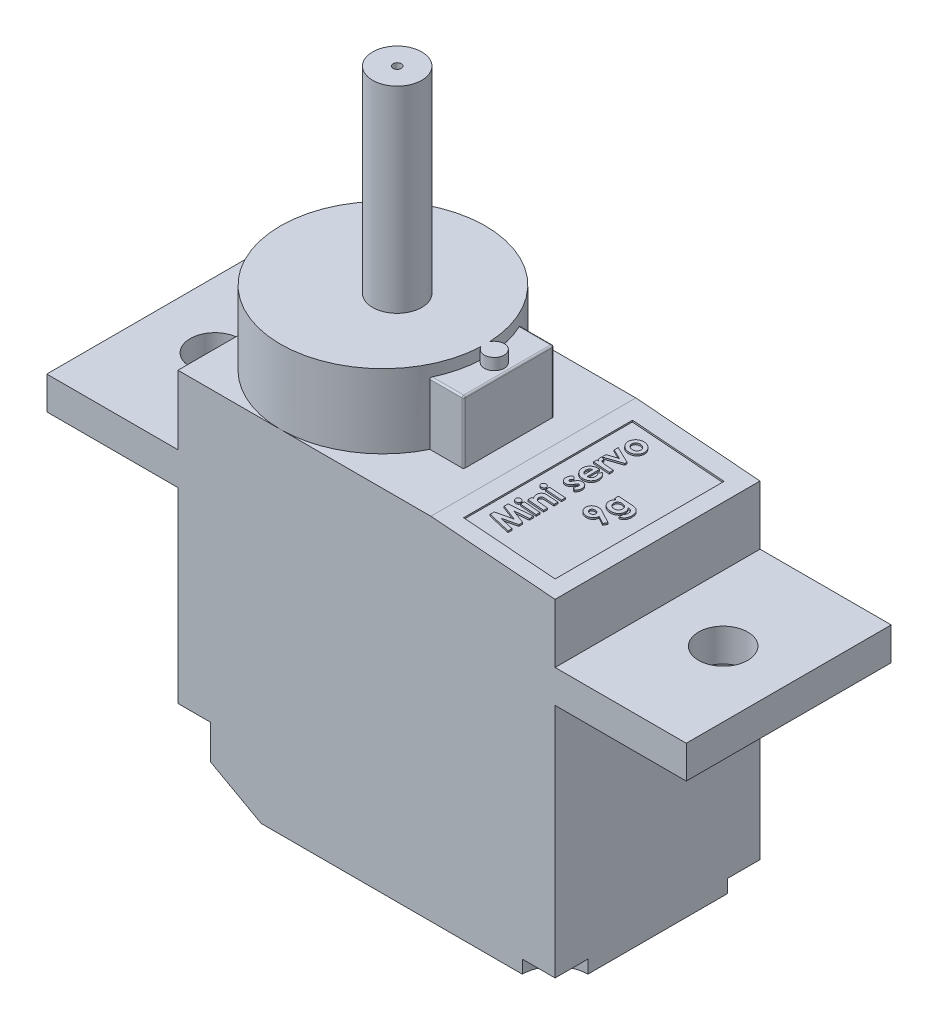
from build123d import *

# Parameters (mm, degrees)
SKETCH1_W                = 23
SKETCH1_H                = 12.5
BOSS_EXTRUDE1_DEPTH      = 15.2
SKETCH2_W                = 39
SKETCH2_H                = 12.5
BOSS_EXTRUDE2_DEPTH      = 2
SKETCH3_W                = 23
SKETCH3_H                = 12.5
BOSS_EXTRUDE3_DEPTH      = 4.2
CUT_EXTRUDE1_DEPTH       = 13.5
SKETCH5_R                = 6.250000507
BOSS_EXTRUDE4_DEPTH      = 4.5
SKETCH6_W                = 4.84744246
SKETCH6_H                = 5.5
BOSS_EXTRUDE5_DEPTH      = 3.8
SKETCH7_R                = 0.605889216
BOSS_EXTRUDE7_DEPTH      = 0.7
SKETCH8_R                = 1.5
BOSS_EXTRUDE8_DEPTH      = 12
CUT_EXTRUDE2_DEPTH       = 13.500001013
SKETCH13_R               = 0.25
CUT_EXTRUDE3_DEPTH       = 16.5
CUT_EXTRUDE12_DEPTH      = 0.8
CUT_EXTRUDE13_DEPTH      = 3.8
SKETCH17_W               = 5.6
SKETCH17_H               = 10.3
CUT_EXTRUDE14_DEPTH      = 0.1
SKETCH19_W               = 0.966746795
SKETCH19_H               = 0.237446581
BOSS_EXTRUDE9_DEPTH      = 0.1
FILLET3_R                = 0.1
F_3_0_3_DIAMETER_HOLE1_D = 3


with BuildPart() as part:
    # Sketch1 → Boss-Extrude1 (new body)
    with BuildSketch(Plane(origin=(0, 0, 0), x_dir=(1, 0, 0), z_dir=(0, 1, 0))):
        Rectangle(SKETCH1_W, SKETCH1_H)
    extrude(amount=BOSS_EXTRUDE1_DEPTH)

    # Sketch2 → Boss-Extrude2 (add)
    with BuildSketch(Plane(origin=(0, 15.2, 0), x_dir=(1, 0, 0), z_dir=(0, 1, 0))):
        Rectangle(SKETCH2_W, SKETCH2_H)
    extrude(amount=BOSS_EXTRUDE2_DEPTH)

    # Sketch3 → Boss-Extrude3 (add)
    with BuildSketch(Plane(origin=(0, 17.2, 0), x_dir=(1, 0, 0), z_dir=(0, 1, 0))):
        Rectangle(SKETCH3_W, SKETCH3_H)
    extrude(amount=BOSS_EXTRUDE3_DEPTH)

    # Sketch4 → Cut-Extrude1 (cut, through all)
    with BuildSketch(Plane.XY.offset(6.25)):
        Polygon((11.5, 20.8), (3.92372123, 21.4), (11.5, 21.4), align=None)
    extrude(amount=-CUT_EXTRUDE1_DEPTH, mode=Mode.SUBTRACT)

    # Sketch5 → Boss-Extrude4 (add)
    with BuildSketch(Plane(origin=(0, 21.4, 0), x_dir=(1, 0, 0), z_dir=(0, 1, 0))):
        with Locations((-5.249999493, 5.07e-07)):
            Circle(SKETCH5_R)
    extrude(amount=BOSS_EXTRUDE4_DEPTH)

    # Sketch6 → Boss-Extrude5 (add)
    with BuildSketch(Plane(origin=(0, 21.4, 0), x_dir=(1, 0, 0), z_dir=(0, 1, 0))):
        Rectangle(SKETCH6_W, SKETCH6_H)
    extrude(amount=BOSS_EXTRUDE5_DEPTH)

    # Sketch7 → Boss-Extrude7 (add)
    with BuildSketch(Plane(origin=(0, 25.2, 0), x_dir=(1, 0, 0), z_dir=(0, 1, 0))):
        with Locations((1.542332806, 0)):
            Circle(SKETCH7_R)
    extrude(amount=BOSS_EXTRUDE7_DEPTH)

    # Sketch8 → Boss-Extrude8 (add)
    with BuildSketch(Plane(origin=(0, 25.9, 0), x_dir=(1, 0, 0), z_dir=(0, 1, 0))):
        with Locations((-4.378885872, 0)):
            Circle(SKETCH8_R)
    extrude(amount=BOSS_EXTRUDE8_DEPTH)

    # Sketch9 → Cut-Extrude2 (cut, through all)
    with BuildSketch(Plane.XY.offset(6.25)):
        Polygon((-11.5, 0), (-6.42062996, 0), (-11.5, 2.8), align=None)
    extrude(amount=-CUT_EXTRUDE2_DEPTH, mode=Mode.SUBTRACT)

    # Sketch13 → Cut-Extrude3 (cut)
    with BuildSketch(Plane(origin=(0, 37.9, 0), x_dir=(1, 0, 0), z_dir=(0, 1, 0))):
        with Locations((-4.378885872, 0)):
            Circle(SKETCH13_R)
    extrude(amount=-CUT_EXTRUDE3_DEPTH, mode=Mode.SUBTRACT)

    # Sketch15 → Cut-Extrude12 (cut)
    with BuildSketch(Plane.XZ):
        with BuildLine():
            Line((9.5, 6.25), (11.5, 6.25))
            Line((11.5, 6.25), (11.5, 4.25))
            ThreePointArc((11.5, 4.25), (10.085786438, 4.835786438), (9.5, 6.25))
        make_face()
        with BuildLine():
            Line((11.5, -6.25), (11.5, -4.25))
            ThreePointArc((11.5, -4.25), (10.085786438, -4.835786438), (9.5, -6.25))
            Line((9.5, -6.25), (11.5, -6.25))
        make_face()
    extrude(amount=-CUT_EXTRUDE12_DEPTH, mode=Mode.SUBTRACT)

    # Sketch16 → Cut-Extrude13 (cut)
    with BuildSketch(Plane.XZ):
        with BuildLine():
            Line((-11.5, 4.25), (-11.5, 6.25))
            Line((-11.5, 6.25), (-9.5, 6.25))
            ThreePointArc((-9.5, 6.25), (-10.085786438, 4.835786438), (-11.5, 4.25))
        make_face()
        with BuildLine():
            Line((-11.5, -6.25), (-9.5, -6.25))
            ThreePointArc((-9.5, -6.25), (-10.085786438, -4.835786438), (-11.5, -4.25))
            Line((-11.5, -4.25), (-11.5, -6.25))
        make_face()
    extrude(amount=-CUT_EXTRUDE13_DEPTH, mode=Mode.SUBTRACT)

    # Sketch17 → Cut-Extrude14 (cut)
    with BuildSketch(Plane(origin=(1.708655801, 21.575421113, 0), x_dir=(0.996878786, -0.078947368, 0), z_dir=(0.078947368, 0.996878786, 0))):
        with Locations((6.02200077, -0.1)):
            Rectangle(SKETCH17_W, SKETCH17_H)
    extrude(amount=-CUT_EXTRUDE14_DEPTH, mode=Mode.SUBTRACT)

    # Sketch19 → Boss-Extrude9 (add)
    with BuildSketch(Plane(origin=(1.700761064, 21.475733235, 0), x_dir=(0.996878786, -0.078947368, 0), z_dir=(0.078947368, 0.996878786, 0))):
        Polygon((3.804977761, -4.209998915), (3.804977761, -3.963542084), (4.727733337, -3.661698718), (3.804977761, -3.357735293), (3.804977761, -3.113663528), (5.127894428, -2.889997329), (5.127894428, -3.130358991), (4.292326269, -3.271607906), (5.127894428, -3.54668553), (5.127894428, -3.77830195), (4.292326269, -4.05178953), (5.127894428, -4.192773437), (5.127894428, -4.433400107), align=None)
        with BuildLine():
            add(Edge.make_bspline(
                [(3.754096351, -2.602199352), (3.75459237, -2.591961906), (3.755566352, -2.571859693), (3.765250821, -2.543162418), (3.779962144, -2.516577279), (3.800736934, -2.493321996), (3.825461159, -2.473783527), (3.853306295, -2.459094906), (3.884008461, -2.450748481), (3.905189995, -2.449608003), (3.916015839, -2.449025107)],
                knots=[0, 0, 0, 0, 3.0615e-05, 6.0115e-05, 8.9897e-05, 0.000121258, 0.000152962, 0.000184016, 0.000215069, 0.000247531, 0.000247531, 0.000247531, 0.000247531], degree=3))
            add(Edge.make_bspline(
                [(3.916015839, -2.449025107), (3.926755073, -2.449605165), (3.947766142, -2.450740036), (3.978075272, -2.459095732), (4.005632722, -2.473557801), (4.02994352, -2.493040352), (4.050299111, -2.516159468), (4.065658572, -2.542001345), (4.074734342, -2.570515674), (4.075802775, -2.590299071), (4.076345283, -2.600344301)],
                knots=[0, 0, 0, 0, 3.2198e-05, 6.2995e-05, 9.3457e-05, 0.000124953, 0.00015594, 0.000185393, 0.000214561, 0.000244648, 0.000244648, 0.000244648, 0.000244648], degree=3))
            add(Edge.make_bspline(
                [(4.076345283, -2.600344301), (4.075838926, -2.610664087), (4.074844674, -2.630927394), (4.065284296, -2.66004514), (4.049948219, -2.686657776), (4.028907377, -2.710017641), (4.004029509, -2.729557175), (3.975889403, -2.743906483), (3.945069935, -2.752707621), (3.923583116, -2.753769392), (3.912570743, -2.754313568)],
                knots=[0, 0, 0, 0, 3.0879e-05, 6.0632e-05, 9.0905e-05, 0.000122442, 0.000154354, 0.000185288, 0.000216666, 0.000249656, 0.000249656, 0.000249656, 0.000249656], degree=3))
            add(Edge.make_bspline(
                [(3.912570743, -2.754313568), (3.902009274, -2.753725713), (3.881262794, -2.752570957), (3.851287745, -2.744252881), (3.824083661, -2.729750005), (3.799821827, -2.710462573), (3.779512344, -2.687309295), (3.764886508, -2.660902407), (3.755672611, -2.632306853), (3.754627196, -2.61233881), (3.754096351, -2.602199352)],
                knots=[0, 0, 0, 0, 3.167e-05, 6.2212e-05, 9.2439e-05, 0.000123562, 0.00015475, 0.000184171, 0.000213591, 0.000243942, 0.000243942, 0.000243942, 0.000243942], degree=3))
        make_face()
        with Locations((4.64452103, -2.601669338)):
            Rectangle(SKETCH19_W, SKETCH19_H)
        with BuildLine():
            Line((4.161147633, -2.262459936), (4.161147633, -2.025013355))
            Line((4.161147633, -2.025013355), (4.263440468, -2.025013355))
            add(Edge.make_bspline(
                [(4.263440468, -2.025013355), (4.252895408, -2.011471852), (4.232741746, -1.985591407), (4.207153626, -1.946137744), (4.185757128, -1.909151347), (4.169870375, -1.873291895), (4.158236054, -1.838291066), (4.150419303, -1.80328736), (4.145017255, -1.768035338), (4.144463712, -1.744302244), (4.144187163, -1.732445246)],
                knots=[0, 0, 0, 0, 5.1465e-05, 9.8359e-05, 0.000140959, 0.000179518, 0.000215804, 0.000251419, 0.000287023, 0.000322569, 0.000322569, 0.000322569, 0.000322569], degree=3))
            add(Edge.make_bspline(
                [(4.144187163, -1.732445246), (4.144472419, -1.720413512), (4.145032681, -1.696782417), (4.15005373, -1.662119501), (4.157614767, -1.628794919), (4.16856507, -1.59683021), (4.182668476, -1.566184116), (4.199989685, -1.537046684), (4.220179715, -1.50914136), (4.235873487, -1.492194884), (4.243829925, -1.483603349)],
                knots=[0, 0, 0, 0, 3.6076e-05, 7.0856e-05, 0.000104861, 0.000138467, 0.000172024, 0.000205884, 0.000240019, 0.000275121, 0.000275121, 0.000275121, 0.000275121], degree=3))
            add(Edge.make_bspline(
                [(4.243829925, -1.483603349), (4.251177599, -1.476696585), (4.265926724, -1.46283251), (4.291171464, -1.445399264), (4.318743463, -1.430347031), (4.348923799, -1.41826973), (4.381735287, -1.409035118), (4.416900166, -1.402131615), (4.454686424, -1.39820407), (4.480649169, -1.397723188), (4.493996859, -1.397475962)],
                knots=[0, 0, 0, 0, 3.0217e-05, 6.0654e-05, 9.1724e-05, 0.000124301, 0.000157936, 0.000193849, 0.00023169, 0.000271728, 0.000271728, 0.000271728, 0.000271728], degree=3))
            Line((4.493996859, -1.397475962), (5.127894428, -1.397475962))
            Line((5.127894428, -1.397475962), (5.127894428, -1.634922543))
            Line((5.127894428, -1.634922543), (4.708122793, -1.634922543))
            add(Edge.make_bspline(
                [(4.708122793, -1.634922543), (4.694430569, -1.634972733), (4.668191963, -1.635068913), (4.630640648, -1.635808044), (4.596726682, -1.637249596), (4.566389395, -1.638567758), (4.53973313, -1.64113921), (4.516512884, -1.64350685), (4.496996733, -1.64701419), (4.476038704, -1.651710565), (4.453705894, -1.659720001), (4.43031827, -1.672584349), (4.410099694, -1.688292983), (4.393521681, -1.707140929), (4.380279706, -1.728484577), (4.371449805, -1.75249671), (4.365584458, -1.778628512), (4.36498473, -1.796895655), (4.364673274, -1.806382295)],
                knots=[0, 0, 0, 0, 4.1077e-05, 7.8716e-05, 0.000112663, 0.000142916, 0.000169788, 0.000192995, 0.000212906, 0.000229234, 0.000257399, 0.000283731, 0.00030902, 0.0003338, 0.000358662, 0.00038391, 0.000410211, 0.000438627, 0.000438627, 0.000438627, 0.000438627], degree=3))
            add(Edge.make_bspline(
                [(4.364673274, -1.806382295), (4.365300058, -1.818714845), (4.366526168, -1.84283971), (4.375733221, -1.877747918), (4.391472627, -1.909699074), (4.412865203, -1.938806589), (4.439740262, -1.964369847), (4.471892035, -1.985267733), (4.508285748, -2.002626573), (4.534841665, -2.010043608), (4.548588372, -2.013883046)],
                knots=[0, 0, 0, 0, 3.6973e-05, 7.2326e-05, 0.000107409, 0.00014324, 0.000180167, 0.000218019, 0.000257852, 0.000300599, 0.000300599, 0.000300599, 0.000300599], degree=3))
            add(Edge.make_bspline(
                [(4.548588372, -2.013883046), (4.552904782, -2.014838435), (4.562531244, -2.016969143), (4.578794152, -2.018720308), (4.598175752, -2.021173637), (4.620852782, -2.02205164), (4.646799373, -2.02367027), (4.675967638, -2.024244313), (4.708473615, -2.024836211), (4.731177961, -2.024952351), (4.743103763, -2.025013355)],
                knots=[0, 0, 0, 0, 1.3253e-05, 2.9557e-05, 4.9018e-05, 7.1847e-05, 9.7587e-05, 0.000127014, 0.000159349, 0.000195126, 0.000195126, 0.000195126, 0.000195126], degree=3))
            Line((4.743103763, -2.025013355), (5.127894428, -2.025013355))
            Line((5.127894428, -2.025013355), (5.127894428, -2.262459936))
            Line((5.127894428, -2.262459936), (4.161147633, -2.262459936))
        make_face()
        with BuildLine():
            add(Edge.make_bspline(
                [(3.754096351, -1.058796575), (3.75459237, -1.048559128), (3.755566352, -1.028456916), (3.765250821, -0.99975964), (3.779962144, -0.973174502), (3.800736934, -0.949919219), (3.825461159, -0.930380749), (3.853306295, -0.915692128), (3.884008461, -0.907345704), (3.905189995, -0.906205225), (3.916015839, -0.905622329)],
                knots=[0, 0, 0, 0, 3.0615e-05, 6.0115e-05, 8.9897e-05, 0.000121258, 0.000152962, 0.000184016, 0.000215069, 0.000247531, 0.000247531, 0.000247531, 0.000247531], degree=3))
            add(Edge.make_bspline(
                [(3.916015839, -0.905622329), (3.926755073, -0.906202387), (3.947766142, -0.907337258), (3.978075272, -0.915692954), (4.005632722, -0.930155023), (4.02994352, -0.949637574), (4.050299111, -0.97275669), (4.065658572, -0.998598568), (4.074734342, -1.027112897), (4.075802775, -1.046896293), (4.076345283, -1.056941523)],
                knots=[0, 0, 0, 0, 3.2198e-05, 6.2995e-05, 9.3457e-05, 0.000124953, 0.00015594, 0.000185393, 0.000214561, 0.000244648, 0.000244648, 0.000244648, 0.000244648], degree=3))
            add(Edge.make_bspline(
                [(4.076345283, -1.056941523), (4.075838926, -1.067261309), (4.074844674, -1.087524616), (4.065284296, -1.116642362), (4.049948219, -1.143254998), (4.028907377, -1.166614864), (4.004029509, -1.186154397), (3.975889403, -1.200503706), (3.945069935, -1.209304843), (3.923583116, -1.210366614), (3.912570743, -1.210910791)],
                knots=[0, 0, 0, 0, 3.0879e-05, 6.0632e-05, 9.0905e-05, 0.000122442, 0.000154354, 0.000185288, 0.000216666, 0.000249656, 0.000249656, 0.000249656, 0.000249656], degree=3))
            add(Edge.make_bspline(
                [(3.912570743, -1.210910791), (3.902009274, -1.210322936), (3.881262794, -1.209168179), (3.851287745, -1.200850104), (3.824083661, -1.186347227), (3.799821827, -1.167059795), (3.779512344, -1.143906517), (3.764886508, -1.117499629), (3.755672611, -1.088904075), (3.754627196, -1.068936033), (3.754096351, -1.058796575)],
                knots=[0, 0, 0, 0, 3.167e-05, 6.2212e-05, 9.2439e-05, 0.000123562, 0.00015475, 0.000184171, 0.000213591, 0.000243942, 0.000243942, 0.000243942, 0.000243942], degree=3))
        make_face()
        with Locations((4.64452103, -1.05826656)):
            Rectangle(SKETCH19_W, SKETCH19_H)
        with BuildLine():
            Line((4.310346768, 0.383373397), (4.466436095, 0.238149372))
            add(Edge.make_bspline(
                [(4.466436095, 0.238149372), (4.458411661, 0.230897641), (4.443063959, 0.217027826), (4.42214161, 0.19579448), (4.404719475, 0.17487734), (4.390084155, 0.154666195), (4.378860614, 0.134748261), (4.370785527, 0.115289102), (4.365659342, 0.09627938), (4.364995777, 0.083678933), (4.364673274, 0.077554921)],
                knots=[0, 0, 0, 0, 3.2445e-05, 6.2054e-05, 8.9335e-05, 0.000114042, 0.000136822, 0.000157737, 0.000177148, 0.000195502, 0.000195502, 0.000195502, 0.000195502], degree=3))
            add(Edge.make_bspline(
                [(4.364673274, 0.077554921), (4.364862134, 0.071358036), (4.365223742, 0.05949293), (4.36832543, 0.042748605), (4.373695023, 0.028037596), (4.38101428, 0.015589477), (4.390030852, 0.005588438), (4.400345598, -0.001413756), (4.411637705, -0.006115794), (4.419658925, -0.006513556), (4.423769912, -0.006717415)],
                knots=[0, 0, 0, 0, 1.8581e-05, 3.5576e-05, 5.0837e-05, 6.5335e-05, 7.8651e-05, 9.0853e-05, 0.000102517, 0.000114779, 0.000114779, 0.000114779, 0.000114779], degree=3))
            add(Edge.make_bspline(
                [(4.423769912, -0.006717415), (4.429999834, -0.006026723), (4.442926199, -0.004593619), (4.457918854, 0.005249822), (4.468978629, 0.018273405), (4.479270384, 0.033285831), (4.490777669, 0.053616541), (4.498657043, 0.069039934), (4.503007108, 0.077554921)],
                knots=[0, 0, 0, 0, 1.8607e-05, 3.8608e-05, 5.1746e-05, 6.9831e-05, 9.3104e-05, 0.000121788, 0.000121788, 0.000121788, 0.000121788], degree=3))
            Line((4.503007108, 0.077554921), (4.546468313, 0.163417301))
            add(Edge.make_bspline(
                [(4.546468313, 0.163417301), (4.552012371, 0.174342414), (4.562768887, 0.195539185), (4.580166995, 0.22531091), (4.596910375, 0.2529569), (4.614548494, 0.277363506), (4.6315577, 0.299650815), (4.649266113, 0.318725676), (4.66663527, 0.335555581), (4.689956301, 0.354300833), (4.721007202, 0.37305852), (4.761391978, 0.388694119), (4.804634, 0.398665374), (4.834563654, 0.399768531), (4.849901723, 0.400333868)],
                knots=[0, 0, 0, 0, 3.6744e-05, 7.1291e-05, 0.000103427, 0.000133648, 0.000161586, 0.00018747, 0.00021165, 0.000234082, 0.000277122, 0.000319837, 0.000363557, 0.000409513, 0.000409513, 0.000409513, 0.000409513], degree=3))
            add(Edge.make_bspline(
                [(4.849901723, 0.400333868), (4.860249279, 0.399992958), (4.880502193, 0.399325709), (4.910315033, 0.395114986), (4.938653049, 0.387529508), (4.96592948, 0.377647433), (4.991566802, 0.364076491), (5.015941096, 0.347877032), (5.039267105, 0.32895112), (5.060771519, 0.306951087), (5.08069072, 0.282714428), (5.097975095, 0.256157985), (5.112234484, 0.227511698), (5.124309895, 0.197156425), (5.133541298, 0.164651356), (5.140075024, 0.130151664), (5.144149087, 0.093641178), (5.144615633, 0.068643987), (5.144854898, 0.055824319)],
                knots=[0, 0, 0, 0, 3.1047e-05, 6.0766e-05, 9.0077e-05, 0.000118923, 0.000147607, 0.00017686, 0.000206619, 0.000237539, 0.000268994, 0.000300601, 0.000332364, 0.000364843, 0.000398478, 0.00043356, 0.000470083, 0.000508532, 0.000508532, 0.000508532, 0.000508532], degree=3))
            add(Edge.make_bspline(
                [(5.144854898, 0.055824319), (5.144314006, 0.038838887), (5.143252284, 0.005497979), (5.135856475, -0.043194003), (5.123054206, -0.08917216), (5.105119865, -0.132474321), (5.082266598, -0.173365705), (5.053910696, -0.211262336), (5.02079095, -0.246821188), (4.995389648, -0.267509698), (4.982405396, -0.278084936)],
                knots=[0, 0, 0, 0, 5.095e-05, 0.000100011, 0.000147334, 0.000193792, 0.000240304, 0.000287476, 0.000335471, 0.000385659, 0.000385659, 0.000385659, 0.000385659], degree=3))
            Line((4.982405396, -0.278084936), (4.822605966, -0.134185948))
            add(Edge.make_bspline(
                [(4.822605966, -0.134185948), (4.829976995, -0.127155304), (4.844652167, -0.113157812), (4.864364835, -0.089970439), (4.881622161, -0.064861726), (4.896561886, -0.038529818), (4.908343449, -0.011961111), (4.917871849, 0.013266089), (4.922989826, 0.037245738), (4.923924579, 0.052713802), (4.924368787, 0.060064436)],
                knots=[0, 0, 0, 0, 3.0545e-05, 6.0813e-05, 9.1099e-05, 0.000121833, 0.000151485, 0.000178225, 0.000202601, 0.000224675, 0.000224675, 0.000224675, 0.000224675], degree=3))
            add(Edge.make_bspline(
                [(4.924368787, 0.060064436), (4.924155729, 0.067418104), (4.923746173, 0.081553884), (4.919488871, 0.101646665), (4.912325846, 0.11944803), (4.902413191, 0.134570882), (4.891022432, 0.147005385), (4.878231414, 0.156115914), (4.86438933, 0.161763388), (4.854721202, 0.162513408), (4.849901723, 0.162887286)],
                knots=[0, 0, 0, 0, 2.2035e-05, 4.2358e-05, 6.1256e-05, 7.9265e-05, 9.6326e-05, 0.000111545, 0.000126063, 0.000140493, 0.000140493, 0.000140493, 0.000140493], degree=3))
            add(Edge.make_bspline(
                [(4.849901723, 0.162887286), (4.845356364, 0.162568182), (4.836023866, 0.161913), (4.822248431, 0.1567259), (4.80860854, 0.148582051), (4.795065737, 0.137286977), (4.781729904, 0.122690382), (4.768707857, 0.104844504), (4.755304854, 0.084161048), (4.747305057, 0.068883071), (4.743103763, 0.060859458)],
                knots=[0, 0, 0, 0, 1.3609e-05, 2.7941e-05, 4.3621e-05, 6.113e-05, 8.0633e-05, 0.000102787, 0.00012734, 0.000154497, 0.000154497, 0.000154497, 0.000154497], degree=3))
            Line((4.743103763, 0.060859458), (4.703352661, -0.017847723))
            add(Edge.make_bspline(
                [(4.703352661, -0.017847723), (4.693778669, -0.035701654), (4.675400194, -0.069974507), (4.643885016, -0.116298592), (4.610336481, -0.155505243), (4.574934824, -0.187626409), (4.537779391, -0.213220617), (4.498397119, -0.231074295), (4.457161363, -0.242305889), (4.428963906, -0.243541544), (4.414759662, -0.244163996)],
                knots=[0, 0, 0, 0, 6.0746e-05, 0.00011661, 0.000167717, 0.000215189, 0.000259657, 0.000302469, 0.000344378, 0.000386919, 0.000386919, 0.000386919, 0.000386919], degree=3))
            add(Edge.make_bspline(
                [(4.414759662, -0.244163996), (4.4055536, -0.243948499), (4.387480604, -0.243525443), (4.360942704, -0.239008963), (4.335419189, -0.232212753), (4.310862392, -0.222494372), (4.287146379, -0.210434323), (4.264810914, -0.194978347), (4.243198378, -0.177225831), (4.223001804, -0.156666391), (4.204607635, -0.13400435), (4.188229119, -0.109823584), (4.174713643, -0.083892204), (4.163557278, -0.056471932), (4.154767991, -0.027568018), (4.148768284, 0.002889111), (4.144959167, 0.034792376), (4.144448144, 0.056608233), (4.144187163, 0.067749649)],
                knots=[0, 0, 0, 0, 2.7593e-05, 5.4169e-05, 8.0526e-05, 0.000106707, 0.000133257, 0.000160158, 0.000188016, 0.000217061, 0.000246447, 0.00027548, 0.000304522, 0.000334, 0.000364181, 0.000395, 0.000427017, 0.000460434, 0.000460434, 0.000460434, 0.000460434], degree=3))
            add(Edge.make_bspline(
                [(4.144187163, 0.067749649), (4.14465733, 0.08316049), (4.145591007, 0.113763994), (4.154281028, 0.158729483), (4.1674315, 0.202421445), (4.186430722, 0.244247137), (4.210096034, 0.283950892), (4.238892919, 0.320568862), (4.272048301, 0.354367016), (4.297453842, 0.37360859), (4.310346768, 0.383373397)],
                knots=[0, 0, 0, 0, 4.6187e-05, 9.1721e-05, 0.000136904, 0.000182808, 0.000229165, 0.000275233, 0.000322267, 0.000370732, 0.000370732, 0.000370732, 0.000370732], degree=3))
        make_face()
        with BuildLine():
            Line((4.703882676, 1.569811281), (4.703882676, 0.80738515))
            add(Edge.make_bspline(
                [(4.703882676, 0.80738515), (4.712740184, 0.808943586), (4.730145885, 0.812006038), (4.755373315, 0.818563015), (4.779130002, 0.827218054), (4.801611091, 0.837172271), (4.822737029, 0.848820193), (4.84222609, 0.862574105), (4.860479341, 0.877834698), (4.877229835, 0.894891072), (4.892283044, 0.913306255), (4.905369645, 0.933130455), (4.916540495, 0.954040769), (4.925556522, 0.976275954), (4.932788557, 0.999657643), (4.937750559, 1.024340866), (4.940688078, 1.050237284), (4.941112374, 1.067879601), (4.941329257, 1.07689762)],
                knots=[0, 0, 0, 0, 2.6975e-05, 5.3008e-05, 7.8072e-05, 0.000102746, 0.000126709, 0.000150309, 0.000174196, 0.000197995, 0.000221918, 0.000245438, 0.000269148, 0.000292918, 0.000317311, 0.000342466, 0.000368337, 0.000395388, 0.000395388, 0.000395388, 0.000395388], degree=3))
            add(Edge.make_bspline(
                [(4.941329257, 1.07689762), (4.941041875, 1.087782888), (4.940475936, 1.109219187), (4.935456898, 1.140623525), (4.927875861, 1.170996094), (4.916602223, 1.200049463), (4.902568525, 1.22812017), (4.885084264, 1.254746084), (4.864660388, 1.28038808), (4.848917672, 1.296032719), (4.840891473, 1.304008914)],
                knots=[0, 0, 0, 0, 3.2635e-05, 6.4267e-05, 9.5184e-05, 0.000126387, 0.000157557, 0.000189164, 0.000221777, 0.000255699, 0.000255699, 0.000255699, 0.000255699], degree=3))
            Line((4.840891473, 1.304008914), (4.935499095, 1.502764423))
            add(Edge.make_bspline(
                [(4.935499095, 1.502764423), (4.944146395, 1.496506806), (4.961280701, 1.484107568), (4.985391064, 1.463864728), (5.007894909, 1.44274586), (5.028607158, 1.420708481), (5.047570511, 1.397861302), (5.064561851, 1.373878538), (5.079870497, 1.348958325), (5.093835037, 1.323229223), (5.105669271, 1.296186971), (5.116408458, 1.268236713), (5.124990924, 1.238834091), (5.132595099, 1.208391768), (5.137996385, 1.176570222), (5.141989872, 1.143585618), (5.144416043, 1.109353309), (5.144706875, 1.08608846), (5.144854898, 1.074247546)],
                knots=[0, 0, 0, 0, 3.2013e-05, 6.3433e-05, 9.4366e-05, 0.000124551, 0.000154104, 0.000183371, 0.000212642, 0.000241808, 0.00027111, 0.000301135, 0.000331569, 0.000362935, 0.000395219, 0.00042832, 0.000462589, 0.000498109, 0.000498109, 0.000498109, 0.000498109], degree=3))
            add(Edge.make_bspline(
                [(5.144854898, 1.074247546), (5.1444835, 1.056030143), (5.143756138, 1.020352408), (5.137005181, 0.968167271), (5.125811366, 0.918605866), (5.110595094, 0.871528247), (5.090504848, 0.827137916), (5.06593281, 0.785412903), (5.037350076, 0.745936317), (5.004156771, 0.709914387), (4.968027831, 0.677097346), (4.929227817, 0.648272897), (4.888027809, 0.624153009), (4.844700478, 0.604345272), (4.799134923, 0.588950011), (4.75131126, 0.57785092), (4.701252331, 0.571047045), (4.667156612, 0.570312193), (4.649821177, 0.569938568)],
                knots=[0, 0, 0, 0, 5.4633e-05, 0.000106995, 0.000157527, 0.000206888, 0.000255161, 0.000303384, 0.000351937, 0.000401085, 0.000450054, 0.00049818, 0.000545812, 0.00059301, 0.000640862, 0.000689845, 0.000740105, 0.00079209, 0.00079209, 0.00079209, 0.00079209], degree=3))
            add(Edge.make_bspline(
                [(4.649821177, 0.569938568), (4.632045227, 0.57031587), (4.597071844, 0.571058193), (4.545857031, 0.577792339), (4.496991172, 0.588980696), (4.450406974, 0.604420992), (4.405958742, 0.623928243), (4.364035343, 0.648355015), (4.324490825, 0.677083042), (4.28751018, 0.70978186), (4.254131107, 0.74595639), (4.224383683, 0.784395246), (4.199596154, 0.825530327), (4.179567847, 0.868896362), (4.163295352, 0.914215964), (4.152467366, 0.962012964), (4.145197022, 1.011923702), (4.144527468, 1.046041583), (4.144187163, 1.063382245)],
                knots=[0, 0, 0, 0, 5.3309e-05, 0.000104882, 0.00015464, 0.000203497, 0.000251903, 0.000299993, 0.000348761, 0.000398322, 0.000447828, 0.000496221, 0.000543896, 0.000591557, 0.000639332, 0.000688057, 0.000738352, 0.000790337, 0.000790337, 0.000790337, 0.000790337], degree=3))
            add(Edge.make_bspline(
                [(4.144187163, 1.063382245), (4.144563588, 1.081687281), (4.145302659, 1.117627333), (4.152009186, 1.170170851), (4.163233887, 1.220079591), (4.178441937, 1.267424143), (4.19854815, 1.312065881), (4.223017494, 1.354042689), (4.251792289, 1.393548424), (4.28490249, 1.429987521), (4.321525451, 1.462992516), (4.361376792, 1.491925134), (4.404138733, 1.516308875), (4.449707993, 1.536287588), (4.498057821, 1.551651519), (4.549143965, 1.562765234), (4.603175099, 1.569515997), (4.640172749, 1.570237346), (4.659096435, 1.570606303)],
                knots=[0, 0, 0, 0, 5.4897e-05, 0.000107786, 0.000158576, 0.000208189, 0.000256703, 0.000305155, 0.000353709, 0.000403052, 0.000452592, 0.00050136, 0.000550501, 0.000599984, 0.000650353, 0.000702438, 0.000756641, 0.000813392, 0.000813392, 0.000813392, 0.000813392], degree=3))
            Line((4.659096435, 1.570606303), (4.703882676, 1.569811281))
        make_face()
        with BuildLine():
            add(Edge.make_bspline(
                [(4.517317505, 1.333159722), (4.505212802, 1.328698144), (4.481216317, 1.319853467), (4.448235811, 1.299469926), (4.41926924, 1.273052621), (4.39389435, 1.241853747), (4.373111704, 1.206462071), (4.358688893, 1.167493173), (4.349189126, 1.126024733), (4.348211629, 1.097357114), (4.347712804, 1.082727781)],
                knots=[0, 0, 0, 0, 3.8631e-05, 7.6583e-05, 0.000115427, 0.000155739, 0.000196828, 0.000237926, 0.000279979, 0.000323802, 0.000323802, 0.000323802, 0.000323802], degree=3))
            add(Edge.make_bspline(
                [(4.347712804, 1.082727781), (4.348379385, 1.066772716), (4.349681364, 1.035608994), (4.359768606, 0.990414475), (4.376339034, 0.948195595), (4.39259033, 0.923045445), (4.400714273, 0.910473007)],
                knots=[0, 0, 0, 0, 4.7826e-05, 9.3414e-05, 0.000138245, 0.000183057, 0.000183057, 0.000183057, 0.000183057], degree=3))
            add(Edge.make_bspline(
                [(4.400714273, 0.910473007), (4.40699967, 0.902630092), (4.42044218, 0.885856536), (4.447433826, 0.86444999), (4.479653579, 0.842821254), (4.504245551, 0.830757926), (4.517317505, 0.82434562)],
                knots=[0, 0, 0, 0, 3.0066e-05, 6.4303e-05, 0.000102743, 0.000146363, 0.000146363, 0.000146363, 0.000146363], degree=3))
            Line((4.517317505, 0.82434562), (4.517317505, 1.333159722))
        make_face(mode=Mode.SUBTRACT)
        with BuildLine():
            Line((4.161147633, 1.740211004), (4.161147633, 1.943736645))
            Line((4.161147633, 1.943736645), (4.280135931, 1.943736645))
            add(Edge.make_bspline(
                [(4.280135931, 1.943736645), (4.269556408, 1.949489116), (4.248878291, 1.960732558), (4.221154724, 1.981510672), (4.197505641, 2.005071327), (4.178081803, 2.03116298), (4.162790597, 2.059356218), (4.152393538, 2.089298761), (4.145264799, 2.1203407), (4.144548962, 2.141568482), (4.144187163, 2.152297426)],
                knots=[0, 0, 0, 0, 3.6092e-05, 7.0543e-05, 0.000103523, 0.000135907, 0.000167802, 0.000199319, 0.000230765, 0.000262901, 0.000262901, 0.000262901, 0.000262901], degree=3))
            add(Edge.make_bspline(
                [(4.144187163, 2.152297426), (4.144518711, 2.160092883), (4.145194538, 2.175983156), (4.150045772, 2.200036549), (4.157313776, 2.224697803), (4.164407907, 2.240790707), (4.168037824, 2.249025107)],
                knots=[0, 0, 0, 0, 2.3375e-05, 4.7647e-05, 7.3386e-05, 0.000100355, 0.000100355, 0.000100355, 0.000100355], degree=3))
            Line((4.168037824, 2.249025107), (4.369178399, 2.175353065))
            add(Edge.make_bspline(
                [(4.369178399, 2.175353065), (4.365996735, 2.168767836), (4.360016431, 2.156390142), (4.352959057, 2.138419878), (4.348652992, 2.122111119), (4.34801049, 2.111771665), (4.347712804, 2.10698117)],
                knots=[0, 0, 0, 0, 2.1933e-05, 4.1226e-05, 5.7873e-05, 7.2245e-05, 7.2245e-05, 7.2245e-05, 7.2245e-05], degree=3))
            add(Edge.make_bspline(
                [(4.347712804, 2.10698117), (4.347908395, 2.102456885), (4.348293156, 2.093556836), (4.35164296, 2.08044029), (4.357300696, 2.067963585), (4.365032019, 2.056034329), (4.374874651, 2.044681076), (4.386765627, 2.033747849), (4.401328625, 2.02397192), (4.417585579, 2.013692371), (4.437468353, 2.004930067), (4.461209231, 1.997419777), (4.489077151, 1.990726984), (4.521221983, 1.986121721), (4.557332049, 1.981670429), (4.597672593, 1.979020938), (4.64211599, 1.977046228), (4.673139088, 1.976925489), (4.689307272, 1.976862563)],
                knots=[0, 0, 0, 0, 1.3557e-05, 2.6669e-05, 4.0311e-05, 5.4498e-05, 6.9157e-05, 8.529e-05, 0.000102789, 0.000121696, 0.000142926, 0.000167732, 0.000196336, 0.000228795, 0.000265084, 0.000305471, 0.00035003, 0.00039853, 0.00039853, 0.00039853, 0.00039853], degree=3))
            Line((4.689307272, 1.976862563), (4.736478579, 1.977657585))
            Line((4.736478579, 1.977657585), (5.127894428, 1.977657585))
            Line((5.127894428, 1.977657585), (5.127894428, 1.740211004))
            Line((5.127894428, 1.740211004), (4.161147633, 1.740211004))
        make_face()
        Polygon((4.161147633, 2.257505342), (4.161147633, 2.499192041), (4.731708447, 2.749358974), (4.161147633, 2.999525908), (4.161147633, 3.241212607), (5.127894428, 2.817730869), (5.127894428, 2.680987079), align=None)
        with BuildLine():
            add(Edge.make_bspline(
                [(4.144187163, 3.862919838), (4.144384274, 3.874146501), (4.144774642, 3.896380379), (4.148106999, 3.929483602), (4.153336085, 3.962072464), (4.16084119, 3.994075583), (4.170048487, 4.025675187), (4.181878379, 4.056535502), (4.195261458, 4.087224595), (4.211252654, 4.116886944), (4.228573983, 4.14576456), (4.24771374, 4.173114777), (4.268422332, 4.198883295), (4.290633096, 4.222984756), (4.314363687, 4.245279241), (4.33935949, 4.266183855), (4.366153691, 4.285112902), (4.394167106, 4.302612828), (4.423204221, 4.318199612), (4.453072078, 4.331732107), (4.483355329, 4.343477505), (4.514423484, 4.352673803), (4.545866699, 4.360287521), (4.578070332, 4.365092311), (4.610703558, 4.368508186), (4.632674932, 4.368891214), (4.643726008, 4.369083868)],
                knots=[0, 0, 0, 0, 3.3673e-05, 6.6687e-05, 9.9711e-05, 0.000132624, 0.000165242, 0.000198368, 0.000231706, 0.000265611, 0.00029938, 0.000332683, 0.000365669, 0.000398488, 0.00043092, 0.00046329, 0.00049616, 0.000529251, 0.000562331, 0.000594944, 0.000627574, 0.000659684, 0.000692081, 0.00072454, 0.00075729, 0.000790433, 0.000790433, 0.000790433, 0.000790433], degree=3))
            add(Edge.make_bspline(
                [(4.643726008, 4.369083868), (4.654863339, 4.368880303), (4.677006878, 4.368475572), (4.709948265, 4.365218831), (4.742298814, 4.359811143), (4.774193544, 4.35289633), (4.805289461, 4.343004433), (4.836110279, 4.331912089), (4.866078183, 4.31778199), (4.895661464, 4.302365348), (4.924144239, 4.285011444), (4.951051048, 4.265751159), (4.976431243, 4.245109509), (5.000422318, 4.223156854), (5.022476084, 4.199418576), (5.042904332, 4.174105043), (5.0619827, 4.147468171), (5.079256613, 4.119307527), (5.094434949, 4.089986205), (5.108119357, 4.059998057), (5.119512629, 4.029167902), (5.128803522, 3.997559499), (5.13599723, 3.965153691), (5.140884001, 3.932022018), (5.144282694, 3.898235834), (5.144662935, 3.875472034), (5.144854898, 3.863979868)],
                knots=[0, 0, 0, 0, 3.3408e-05, 6.6422e-05, 9.9185e-05, 0.000131781, 0.000164221, 0.000197006, 0.00022997, 0.000263518, 0.00029706, 0.00032993, 0.00036271, 0.000395154, 0.000427405, 0.000459812, 0.000492682, 0.000525634, 0.000558823, 0.000591678, 0.000624463, 0.000657334, 0.000690448, 0.000723954, 0.00075776, 0.000792227, 0.000792227, 0.000792227, 0.000792227], degree=3))
            add(Edge.make_bspline(
                [(5.144854898, 3.863979868), (5.144361022, 3.847176311), (5.143387586, 3.814056245), (5.136737867, 3.765272454), (5.12524152, 3.718429658), (5.109377995, 3.673309923), (5.088425821, 3.630329261), (5.063574482, 3.588905662), (5.033444157, 3.549875299), (4.999713438, 3.512849248), (4.962582956, 3.479183704), (4.923200715, 3.449476696), (4.881691863, 3.424506735), (4.838223134, 3.403901001), (4.792720984, 3.388014398), (4.745341284, 3.376537239), (4.695945497, 3.369870386), (4.662384774, 3.368906405), (4.645316053, 3.368416132)],
                knots=[0, 0, 0, 0, 5.0408e-05, 9.9355e-05, 0.000147368, 0.000194893, 0.000242541, 0.000290581, 0.000339555, 0.0003902, 0.000440667, 0.000489693, 0.000537959, 0.000585733, 0.000633757, 0.000682286, 0.000731758, 0.00078296, 0.00078296, 0.00078296, 0.00078296], degree=3))
            add(Edge.make_bspline(
                [(4.645316053, 3.368416132), (4.627090382, 3.368923479), (4.591268191, 3.36992066), (4.538787864, 3.377838711), (4.488540439, 3.390482985), (4.440666473, 3.408633043), (4.395077668, 3.431818146), (4.351870177, 3.460121902), (4.311034214, 3.493684191), (4.286335223, 3.519386184), (4.273775755, 3.532455679)],
                knots=[0, 0, 0, 0, 5.4656e-05, 0.000107425, 0.000158844, 0.000209836, 0.00026068, 0.000311985, 0.000364511, 0.000418853, 0.000418853, 0.000418853, 0.000418853], degree=3))
            add(Edge.make_bspline(
                [(4.273775755, 3.532455679), (4.263365369, 3.544448248), (4.242827832, 3.568107103), (4.216779333, 3.606544956), (4.194281377, 3.64590098), (4.175783873, 3.686646874), (4.161837053, 3.728896227), (4.151685016, 3.772432535), (4.145449338, 3.817246745), (4.144610026, 3.847618106), (4.144187163, 3.862919838)],
                knots=[0, 0, 0, 0, 4.7605e-05, 9.3914e-05, 0.000139012, 0.000183491, 0.000227906, 0.000272261, 0.00031746, 0.000363355, 0.000363355, 0.000363355, 0.000363355], degree=3))
        make_face()
        with BuildLine():
            add(Edge.make_bspline(
                [(4.364673274, 3.868219985), (4.364967766, 3.859023545), (4.365547476, 3.840920252), (4.368930707, 3.814347082), (4.374970655, 3.788977887), (4.384022748, 3.764993219), (4.394672475, 3.741785332), (4.408357737, 3.720008385), (4.424430209, 3.699498317), (4.442567651, 3.680174762), (4.462846251, 3.662912363), (4.484548189, 3.647603438), (4.507545273, 3.634517821), (4.532193721, 3.624286023), (4.557952671, 3.615927215), (4.585233823, 3.610249934), (4.613753217, 3.606304657), (4.633288386, 3.606011429), (4.643195994, 3.605862714)],
                knots=[0, 0, 0, 0, 2.7593e-05, 5.4316e-05, 8.0219e-05, 0.000105623, 0.00013111, 0.000156701, 0.00018257, 0.00020919, 0.000236066, 0.000262313, 0.000288774, 0.000315255, 0.000342242, 0.000369894, 0.000398754, 0.000428454, 0.000428454, 0.000428454, 0.000428454], degree=3))
            add(Edge.make_bspline(
                [(4.643195994, 3.605862714), (4.653453111, 3.606036512), (4.673498677, 3.606376166), (4.702767121, 3.609896291), (4.730545607, 3.615694832), (4.756777657, 3.623954211), (4.781628773, 3.634237305), (4.804862064, 3.647112712), (4.826594713, 3.662232607), (4.846741686, 3.679464783), (4.86493274, 3.698461082), (4.88102089, 3.718860656), (4.894156089, 3.740837459), (4.90557151, 3.763647189), (4.913901521, 3.787927454), (4.920154778, 3.813269986), (4.9234952, 3.839952431), (4.924073587, 3.858141531), (4.924368787, 3.867424963)],
                knots=[0, 0, 0, 0, 3.0759e-05, 6.0113e-05, 8.8283e-05, 0.000115775, 0.0001425, 0.000168832, 0.000195297, 0.000221799, 0.000248227, 0.000274096, 0.000299548, 0.000324911, 0.000350474, 0.000376377, 0.000403101, 0.000430959, 0.000430959, 0.000430959, 0.000430959], degree=3))
            add(Edge.make_bspline(
                [(4.924368787, 3.867424963), (4.924107565, 3.876713394), (4.923595417, 3.894924109), (4.919760243, 3.921632876), (4.913724434, 3.947123137), (4.905206178, 3.971506972), (4.894033326, 3.994587207), (4.880348511, 4.0164523), (4.864455163, 4.037294202), (4.845844891, 4.056427033), (4.825657474, 4.074133407), (4.803770145, 4.089677394), (4.780414997, 4.102566167), (4.755723034, 4.113410131), (4.72955403, 4.121490359), (4.701958163, 4.127267782), (4.67307819, 4.131201933), (4.653279741, 4.131490376), (4.643195994, 4.131637286)],
                knots=[0, 0, 0, 0, 2.7857e-05, 5.4616e-05, 8.0777e-05, 0.00010634, 0.000131942, 0.000157533, 0.000183611, 0.000210414, 0.000237463, 0.00026408, 0.000290772, 0.000317357, 0.000344849, 0.000372761, 0.000401884, 0.000432113, 0.000432113, 0.000432113, 0.000432113], degree=3))
            add(Edge.make_bspline(
                [(4.643195994, 4.131637286), (4.633115411, 4.131461191), (4.613334036, 4.131115634), (4.584420095, 4.127596454), (4.556977492, 4.121850572), (4.531123404, 4.11350024), (4.506562877, 4.103193642), (4.483421629, 4.09046424), (4.461813634, 4.075181997), (4.441846038, 4.057856856), (4.423836329, 4.038695339), (4.40777604, 4.018368889), (4.394492948, 3.996412703), (4.383542938, 3.973238691), (4.375118468, 3.948785198), (4.368865039, 3.923079679), (4.36556265, 3.896043352), (4.364972831, 3.87759137), (4.364673274, 3.868219985)],
                knots=[0, 0, 0, 0, 3.0229e-05, 5.932e-05, 8.7231e-05, 0.000114218, 0.000140699, 0.000167031, 0.000193278, 0.000219954, 0.000246199, 0.000272068, 0.00029752, 0.000323007, 0.00034882, 0.000374981, 0.000402231, 0.000430353, 0.000430353, 0.000430353, 0.000430353], degree=3))
        make_face(mode=Mode.SUBTRACT)
        with BuildLine():
            Line((6.554701107, 0.620819979), (6.554701107, 0.87522703))
            Line((6.554701107, 0.87522703), (7.379403965, 0.87522703))
            add(Edge.make_bspline(
                [(7.379403965, 0.87522703), (7.399111173, 0.874916189), (7.437254612, 0.874314555), (7.492416239, 0.869871399), (7.543533659, 0.862280351), (7.59064003, 0.85152902), (7.633739116, 0.83747211), (7.672926328, 0.820629152), (7.708102575, 0.800555468), (7.728686082, 0.784320277), (7.738753925, 0.77637929)],
                knots=[0, 0, 0, 0, 5.9118e-05, 0.000114423, 0.000165882, 0.00021403, 0.0002592, 0.000301689, 0.000341824, 0.00038025, 0.00038025, 0.00038025, 0.00038025], degree=3))
            add(Edge.make_bspline(
                [(7.738753925, 0.77637929), (7.751283479, 0.76495645), (7.776279152, 0.742168599), (7.807822806, 0.701992342), (7.834782602, 0.657977772), (7.856877446, 0.609675714), (7.873706669, 0.5571437), (7.885826708, 0.50051668), (7.89337564, 0.439758754), (7.894169872, 0.39779488), (7.894578244, 0.376218199)],
                knots=[0, 0, 0, 0, 5.0791e-05, 0.000101325, 0.000152592, 0.000205362, 0.000260254, 0.000317743, 0.000378881, 0.000443587, 0.000443587, 0.000443587, 0.000443587], degree=3))
            add(Edge.make_bspline(
                [(7.894578244, 0.376218199), (7.894225152, 0.353410399), (7.893546064, 0.309545125), (7.886903034, 0.246511632), (7.875972385, 0.189094194), (7.860583581, 0.137023179), (7.840727574, 0.089813469), (7.816919075, 0.046574808), (7.788454055, 0.007390235), (7.756454706, -0.028332543), (7.720218307, -0.059765048), (7.680076627, -0.086605324), (7.636398888, -0.109471843), (7.605164309, -0.120762447), (7.589289782, -0.126500735)],
                knots=[0, 0, 0, 0, 6.8405e-05, 0.00013156, 0.000189874, 0.000243534, 0.00029413, 0.000343241, 0.000391269, 0.000439115, 0.000486831, 0.000534754, 0.000583705, 0.000634297, 0.000634297, 0.000634297, 0.000634297], degree=3))
            Line((7.589289782, -0.126500735), (7.589289782, 0.137446581))
            add(Edge.make_bspline(
                [(7.589289782, 0.137446581), (7.596004795, 0.143546121), (7.609520155, 0.155822715), (7.626670231, 0.177536665), (7.641349859, 0.201557214), (7.65337011, 0.22807816), (7.662510432, 0.257210085), (7.669454623, 0.288754681), (7.673368038, 0.322853244), (7.673845848, 0.34635095), (7.674092133, 0.358462707)],
                knots=[0, 0, 0, 0, 2.7177e-05, 5.47e-05, 8.2651e-05, 0.00011147, 0.000141809, 0.000174088, 0.000208241, 0.000244572, 0.000244572, 0.000244572, 0.000244572], degree=3))
            add(Edge.make_bspline(
                [(7.674092133, 0.358462707), (7.673761792, 0.373761388), (7.673131129, 0.402968465), (7.667731516, 0.444432585), (7.658270965, 0.481248666), (7.64496631, 0.513281339), (7.62879073, 0.540842077), (7.610079565, 0.5639756), (7.589182293, 0.582786164), (7.569770268, 0.5953273), (7.552216841, 0.602633147), (7.537059228, 0.607823605), (7.519570989, 0.611459234), (7.500075557, 0.615061921), (7.478385566, 0.617609224), (7.45442116, 0.619343865), (7.428359778, 0.620833185), (7.410235549, 0.620824478), (7.40086956, 0.620819979)],
                knots=[0, 0, 0, 0, 4.5884e-05, 8.7598e-05, 0.000125136, 0.000159587, 0.000191311, 0.000220697, 0.000248471, 0.000275382, 0.000289509, 0.000305432, 0.000323368, 0.000343018, 0.00036491, 0.000388833, 0.000415102, 0.000443194, 0.000443194, 0.000443194, 0.000443194], degree=3))
            add(Edge.make_bspline(
                [(7.40086956, 0.620819979), (7.41107193, 0.61041747), (7.430980765, 0.590118084), (7.456383704, 0.557165989), (7.477352806, 0.52343077), (7.494068777, 0.488731818), (7.506150319, 0.45231126), (7.515473783, 0.414169544), (7.52025632, 0.373512792), (7.521044892, 0.345664293), (7.521447902, 0.331431958)],
                knots=[0, 0, 0, 0, 4.3681e-05, 8.5239e-05, 0.00012451, 0.000162679, 0.000200475, 0.000239427, 0.000280285, 0.000322991, 0.000322991, 0.000322991, 0.000322991], degree=3))
            add(Edge.make_bspline(
                [(7.521447902, 0.331431958), (7.521084179, 0.315682548), (7.520369698, 0.284745122), (7.513422454, 0.239305677), (7.502621952, 0.195705662), (7.487555484, 0.153850864), (7.467645657, 0.114040188), (7.443530548, 0.076081602), (7.414794462, 0.040155124), (7.382538175, 0.006145979), (7.346729043, -0.024627412), (7.308288958, -0.05159814), (7.267603708, -0.074561301), (7.224370159, -0.093100042), (7.178959312, -0.1077421), (7.131207832, -0.118047156), (7.081168044, -0.124214066), (7.047014087, -0.125026389), (7.02959427, -0.125440705)],
                knots=[0, 0, 0, 0, 4.7219e-05, 9.2755e-05, 0.000137553, 0.000181817, 0.000225905, 0.000270823, 0.000316474, 0.000363709, 0.000411252, 0.000457864, 0.000504376, 0.000551144, 0.000598746, 0.000647295, 0.000697488, 0.000749738, 0.000749738, 0.000749738, 0.000749738], degree=3))
            add(Edge.make_bspline(
                [(7.02959427, -0.125440705), (7.011021298, -0.125082381), (6.97472274, -0.12438208), (6.921710617, -0.117480604), (6.871421263, -0.106838453), (6.823910105, -0.0913577), (6.779219022, -0.071466515), (6.737396355, -0.047090945), (6.697971496, -0.018859516), (6.674587303, 0.00350029), (6.662824104, 0.01474818)],
                knots=[0, 0, 0, 0, 5.5692e-05, 0.000108843, 0.000160094, 0.000209707, 0.000258463, 0.000306553, 0.000354736, 0.000403509, 0.000403509, 0.000403509, 0.000403509], degree=3))
            add(Edge.make_bspline(
                [(6.662824104, 0.01474818), (6.652766058, 0.025401965), (6.632982297, 0.04635752), (6.608009691, 0.081053532), (6.58583944, 0.116444468), (6.568466397, 0.153936575), (6.554364629, 0.192694859), (6.545175198, 0.233322698), (6.538605293, 0.275213941), (6.538030922, 0.303756331), (6.537740637, 0.318181591)],
                knots=[0, 0, 0, 0, 4.3907e-05, 8.6362e-05, 0.000127995, 0.000169012, 0.000210084, 0.000251479, 0.000293792, 0.000337028, 0.000337028, 0.000337028, 0.000337028], degree=3))
            add(Edge.make_bspline(
                [(6.537740637, 0.318181591), (6.538113166, 0.331713765), (6.538851355, 0.358528626), (6.544268521, 0.398207167), (6.553239637, 0.436743557), (6.566166359, 0.474403023), (6.583241465, 0.511460175), (6.605062979, 0.548259427), (6.631283087, 0.58523894), (6.651743489, 0.608714555), (6.662294089, 0.620819979)],
                knots=[0, 0, 0, 0, 4.0589e-05, 8.0429e-05, 0.000119897, 0.000159118, 0.000199671, 0.000242077, 0.0002873, 0.000335449, 0.000335449, 0.000335449, 0.000335449], degree=3))
            Line((6.662294089, 0.620819979), (6.554701107, 0.620819979))
        make_face()
        with BuildLine():
            add(Edge.make_bspline(
                [(6.758226748, 0.374893162), (6.758526044, 0.365610224), (6.759115279, 0.347334511), (6.762430925, 0.320473154), (6.768702461, 0.294988565), (6.776803964, 0.270537534), (6.787838123, 0.247578003), (6.800757217, 0.225528232), (6.816679623, 0.205211343), (6.834243534, 0.185805436), (6.853919464, 0.168501978), (6.875215951, 0.153595308), (6.897293061, 0.140441109), (6.920964904, 0.130188588), (6.945622962, 0.121717162), (6.97175982, 0.116538342), (6.998900252, 0.112400785), (7.017474807, 0.112139222), (7.026944196, 0.112005876)],
                knots=[0, 0, 0, 0, 2.7857e-05, 5.4844e-05, 8.1005e-05, 0.000106481, 0.000131969, 0.000157283, 0.000182991, 0.000209249, 0.000235725, 0.000261387, 0.000287158, 0.000312666, 0.000338645, 0.000365205, 0.000392489, 0.000420865, 0.000420865, 0.000420865, 0.000420865], degree=3))
            add(Edge.make_bspline(
                [(7.026944196, 0.112005876), (7.036764093, 0.112150208), (7.056036851, 0.112433478), (7.084113661, 0.116399512), (7.110984853, 0.122064937), (7.136322437, 0.130623018), (7.160459254, 0.141336974), (7.183383746, 0.154206815), (7.204546667, 0.170094324), (7.224418052, 0.187735355), (7.242371683, 0.207256707), (7.258032389, 0.228249338), (7.271412455, 0.250405602), (7.282425623, 0.273804783), (7.290440175, 0.298627323), (7.296764528, 0.324449137), (7.300071116, 0.351575964), (7.300661797, 0.370027254), (7.300961791, 0.379398287)],
                knots=[0, 0, 0, 0, 2.9435e-05, 5.777e-05, 8.4904e-05, 0.000111721, 0.000137821, 0.000164052, 0.000190394, 0.000217045, 0.000243678, 0.000269808, 0.000295487, 0.000321214, 0.000347193, 0.000373611, 0.000400861, 0.000428983, 0.000428983, 0.000428983, 0.000428983], degree=3))
            add(Edge.make_bspline(
                [(7.300961791, 0.379398287), (7.300817673, 0.388600582), (7.300535104, 0.406643374), (7.296564334, 0.432960892), (7.290834757, 0.458112021), (7.282598567, 0.482019119), (7.271982225, 0.504709301), (7.258777484, 0.525953781), (7.243727742, 0.546354501), (7.22588282, 0.564945729), (7.206499288, 0.582137211), (7.185442706, 0.597072374), (7.16293311, 0.609601695), (7.139009742, 0.620045168), (7.113451876, 0.627859209), (7.086530428, 0.633775643), (7.058129956, 0.637250056), (7.038702351, 0.637601369), (7.028799248, 0.637780449)],
                knots=[0, 0, 0, 0, 2.7581e-05, 5.4078e-05, 7.9662e-05, 0.000104888, 0.000129783, 0.000154644, 0.00017982, 0.00020569, 0.000231792, 0.000257454, 0.000282962, 0.000308956, 0.00033561, 0.000363003, 0.000391567, 0.000421267, 0.000421267, 0.000421267, 0.000421267], degree=3))
            add(Edge.make_bspline(
                [(7.028799248, 0.637780449), (7.018982968, 0.637609521), (6.99981619, 0.637275776), (6.971699877, 0.633702194), (6.94508322, 0.627967714), (6.919785232, 0.619908022), (6.895906983, 0.609669038), (6.873551803, 0.596761445), (6.852442528, 0.581866415), (6.832926218, 0.564775076), (6.815522953, 0.545616063), (6.800055328, 0.525334984), (6.787204063, 0.503488567), (6.776576339, 0.480428201), (6.768314096, 0.455903598), (6.762631648, 0.430037983), (6.758652823, 0.402929931), (6.758370618, 0.384360129), (6.758226748, 0.374893162)],
                knots=[0, 0, 0, 0, 2.9435e-05, 5.7473e-05, 8.4866e-05, 0.000111015, 0.000137009, 0.000162647, 0.000188309, 0.000214411, 0.000240295, 0.000265842, 0.000290793, 0.000316169, 0.000341897, 0.000368255, 0.000395539, 0.000423915, 0.000423915, 0.000423915, 0.000423915], degree=3))
        make_face(mode=Mode.SUBTRACT)
        with BuildLine():
            Line((7.555368842, -0.764638421), (7.449365904, -0.975054253))
            Line((7.449365904, -0.975054253), (6.995673329, -0.744497863))
            add(Edge.make_bspline(
                [(6.995673329, -0.744497863), (6.995326102, -0.758119643), (6.994644409, -0.784862493), (6.988980355, -0.82423961), (6.979309429, -0.861893616), (6.966441935, -0.898274885), (6.94916575, -0.932855939), (6.928614732, -0.966195177), (6.903546271, -0.997422084), (6.87578922, -1.027284528), (6.84502602, -1.054297397), (6.8121561, -1.07815428), (6.777495826, -1.098355344), (6.740812287, -1.114571909), (6.702471064, -1.127308468), (6.662321754, -1.136702374), (6.620209927, -1.141958151), (6.591551165, -1.142694204), (6.576961724, -1.14306891)],
                knots=[0, 0, 0, 0, 4.0853e-05, 8.0205e-05, 0.000119026, 0.000157335, 0.000195735, 0.000234781, 0.000274597, 0.000315656, 0.000356964, 0.000397198, 0.000437334, 0.000477076, 0.000517301, 0.000558378, 0.000600584, 0.000644349, 0.000644349, 0.000644349, 0.000644349], degree=3))
            add(Edge.make_bspline(
                [(6.576961724, -1.14306891), (6.562809749, -1.142722055), (6.534923575, -1.142038583), (6.493998959, -1.136351073), (6.454692982, -1.127018703), (6.416994818, -1.114092148), (6.381096427, -1.097258853), (6.346783907, -1.076921011), (6.314188497, -1.052775662), (6.28373498, -1.025021046), (6.255746541, -0.994949421), (6.23165788, -0.962597791), (6.210633234, -0.929210877), (6.194022095, -0.89387029), (6.180521284, -0.857232601), (6.171391989, -0.818793998), (6.165638832, -0.778947196), (6.164955884, -0.751849708), (6.164610295, -0.738137687)],
                knots=[0, 0, 0, 0, 4.2442e-05, 8.3631e-05, 0.000123676, 0.000163484, 0.000202964, 0.000242414, 0.000282961, 0.000324425, 0.000365872, 0.000405994, 0.000445265, 0.000484026, 0.000522924, 0.000562196, 0.000602334, 0.000643452, 0.000643452, 0.000643452, 0.000643452], degree=3))
            add(Edge.make_bspline(
                [(6.164610295, -0.738137687), (6.164905473, -0.723803387), (6.1654859, -0.695616927), (6.171886368, -0.654354413), (6.181714746, -0.614881185), (6.195032189, -0.57701293), (6.213201797, -0.54135038), (6.23454675, -0.507214016), (6.260394672, -0.475265421), (6.289473981, -0.445340792), (6.321372675, -0.4184009), (6.35448696, -0.394382463), (6.388918862, -0.373966019), (6.424692361, -0.357657405), (6.461561653, -0.344689869), (6.499608299, -0.335854085), (6.538794901, -0.329972548), (6.565368066, -0.329304464), (6.578816776, -0.328966346)],
                knots=[0, 0, 0, 0, 4.2971e-05, 8.4497e-05, 0.000124925, 0.00016491, 0.000204612, 0.000244755, 0.00028548, 0.000327646, 0.000369756, 0.000410575, 0.000450253, 0.000489621, 0.000528341, 0.000567294, 0.000606645, 0.000646969, 0.000646969, 0.000646969, 0.000646969], degree=3))
            add(Edge.make_bspline(
                [(6.578816776, -0.328966346), (6.589073558, -0.329152046), (6.609733023, -0.329526088), (6.640629799, -0.333158039), (6.671605961, -0.338744348), (6.697697498, -0.345259228), (6.71978027, -0.35181234), (6.738460696, -0.358626482), (6.759276625, -0.366844656), (6.782260094, -0.376356724), (6.807297243, -0.387239108), (6.834301063, -0.399862748), (6.863685338, -0.41343033), (6.883777316, -0.423432622), (6.894175516, -0.428609108)],
                knots=[0, 0, 0, 0, 3.0759e-05, 6.1956e-05, 9.3196e-05, 0.00012514, 0.000142579, 0.000162277, 0.000184766, 0.000209718, 0.000236895, 0.000266657, 0.000299141, 0.000333985, 0.000333985, 0.000333985, 0.000333985], degree=3))
            Line((6.894175516, -0.428609108), (7.555368842, -0.764638421))
        make_face()
        with BuildLine():
            add(Edge.make_bspline(
                [(6.775187218, -0.73283754), (6.774518461, -0.72145914), (6.773211862, -0.699228324), (6.763077743, -0.667311328), (6.745788437, -0.638632247), (6.722498492, -0.613475641), (6.694499576, -0.592533843), (6.662687683, -0.577188796), (6.627569443, -0.567885433), (6.603078714, -0.566913191), (6.590477099, -0.566412927)],
                knots=[0, 0, 0, 0, 3.4095e-05, 6.6615e-05, 9.9292e-05, 0.000133804, 0.000168839, 0.000203567, 0.000239176, 0.00027692, 0.00027692, 0.00027692, 0.00027692], degree=3))
            add(Edge.make_bspline(
                [(6.590477099, -0.566412927), (6.577611818, -0.56701112), (6.552585776, -0.568174749), (6.516566279, -0.577638186), (6.48400679, -0.593809298), (6.455703628, -0.61580917), (6.432017496, -0.641493733), (6.414715415, -0.670215559), (6.404016363, -0.70127722), (6.402714549, -0.722772977), (6.402056876, -0.733632562)],
                knots=[0, 0, 0, 0, 3.8557e-05, 7.5003e-05, 0.000110795, 0.000146892, 0.000181974, 0.000215015, 0.00024686, 0.000279374, 0.000279374, 0.000279374, 0.000279374], degree=3))
            add(Edge.make_bspline(
                [(6.402056876, -0.733632562), (6.402699297, -0.745109323), (6.403960684, -0.76764385), (6.41461571, -0.799988287), (6.431627668, -0.82966974), (6.455102502, -0.855982824), (6.483287958, -0.87822765), (6.515951645, -0.894044884), (6.551738514, -0.903958843), (6.576806807, -0.905057864), (6.589682077, -0.905622329)],
                knots=[0, 0, 0, 0, 3.4359e-05, 6.7464e-05, 0.000101057, 0.000136358, 0.000172616, 0.000208053, 0.000244567, 0.000283125, 0.000283125, 0.000283125, 0.000283125], degree=3))
            add(Edge.make_bspline(
                [(6.589682077, -0.905622329), (6.602376471, -0.905035956), (6.627065743, -0.903895522), (6.662422066, -0.894289698), (6.694547027, -0.878790314), (6.722584623, -0.857171257), (6.745993076, -0.831173024), (6.763081413, -0.801205058), (6.773240176, -0.767929192), (6.774526521, -0.74474532), (6.775187218, -0.73283754)],
                knots=[0, 0, 0, 0, 3.8029e-05, 7.3963e-05, 0.000109045, 0.000144399, 0.000179501, 0.000213324, 0.000247109, 0.000282787, 0.000282787, 0.000282787, 0.000282787], degree=3))
        make_face(mode=Mode.SUBTRACT)
    extrude(amount=BOSS_EXTRUDE9_DEPTH)

    # Fillet3
    fillet3_edges = [part.edges().sort_by_distance(p)[0] for p in [
        (2.42372123, 23.3, -2.75),
        (1.393104314, 25.2, -2.75),
        (1.393104066, 25.2, 2.75),
        (2.42372123, 25.2, 0),
        (2.42372123, 23.3, 2.75),
    ]]
    fillet(fillet3_edges, radius=FILLET3_R)

    # Ø3.0 (3) Diameter Hole1 (through all)
    with Locations(Plane(origin=(0, 17.2, 0), x_dir=(1, 0, 0), z_dir=(0, 1, 0))):
        with Locations((-15.5, 0)):
            f_3_0_3_diameter_hole1 = Hole(F_3_0_3_DIAMETER_HOLE1_D / 2)

    # Mirror1: Ø3.0 (3) Diameter Hole1 across plane
    add(f_3_0_3_diameter_hole1.mirror(Plane(origin=(0, 0, 0), x_dir=(0, 0, 1), z_dir=(1, 0, 0))), mode=Mode.SUBTRACT)


solid = part.part
